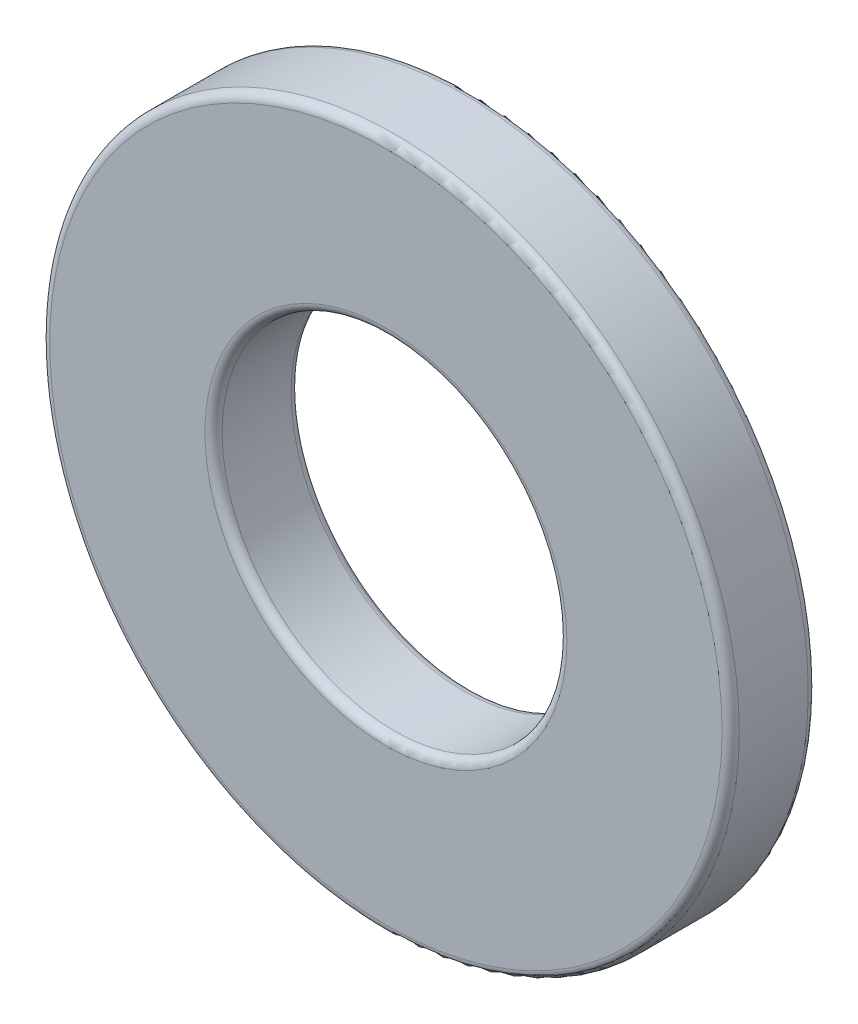
from build123d import *

# Parameters (mm, degrees)
SKETCH3_R                = 6
SKETCH3_R_2              = 3
BOSS_EXTRUDE1_DEPTH      = 0.75
BOSS_EXTRUDE1_DEPTH_BACK = 0.75
FILLET1_R                = 0.15


with BuildPart() as part:
    # Sketch3 → Boss-Extrude1 (new body, two sides)
    with BuildSketch(Plane.XY) as boss_extrude1_sk:
        Circle(SKETCH3_R)
        Circle(SKETCH3_R_2, mode=Mode.SUBTRACT)
    extrude(amount=BOSS_EXTRUDE1_DEPTH)
    extrude(boss_extrude1_sk.sketch, amount=-BOSS_EXTRUDE1_DEPTH_BACK)

    # Fillet1
    fillet1_edges = [part.edges().sort_by_distance(p)[0] for p in [
        (-6, 0, 0.75),
        (-3, 0, 0.75),
        (-6, 0, -0.75),
        (-3, 0, -0.75),
    ]]
    fillet(fillet1_edges, radius=FILLET1_R)


solid = part.part
